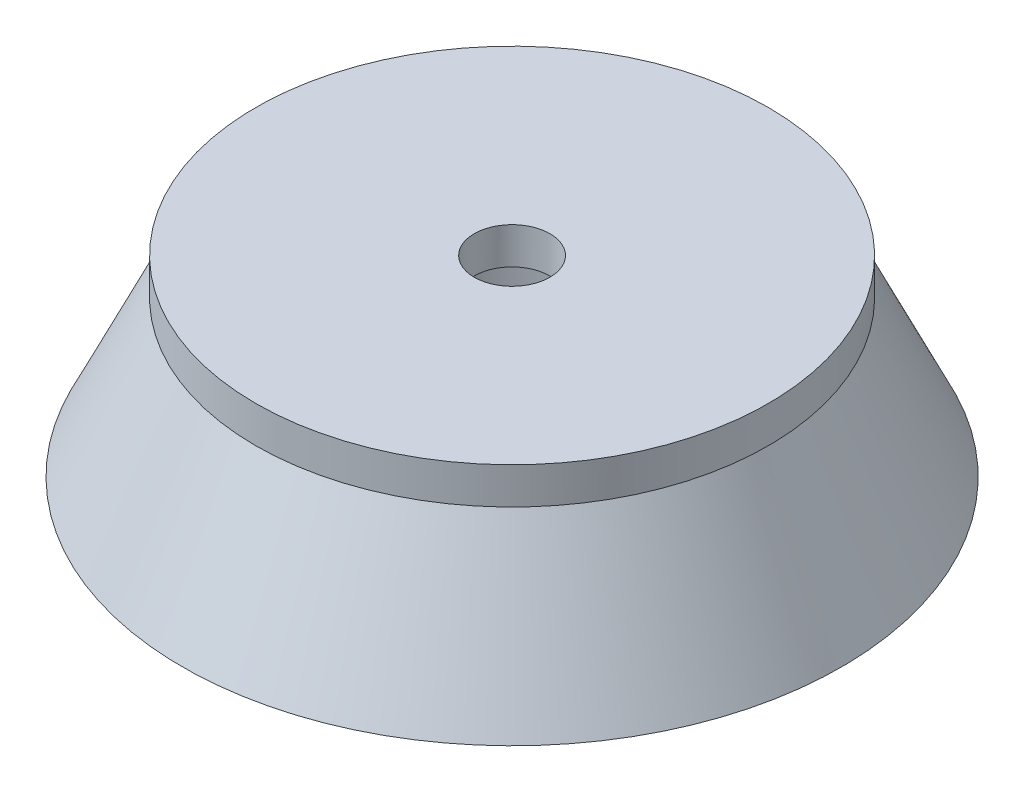
from build123d import *

# Parameters (mm, degrees)
CROQUIS3_R              = 35
SALIENTE_EXTRUIR1_DEPTH = 5
CROQUIS4_R              = 5.16
CORTAR_EXTRUIR1_DEPTH   = 69.806581081
CROQUIS5_R              = 15
CORTAR_EXTRUIR2_DEPTH   = 21.16
CORTAR_EXTRUIR4_DEPTH   = 5


with BuildPart() as part:
    # Croquis2 → Revolución1 (revolve)
    with BuildSketch(Plane.XY, mode=Mode.PRIVATE) as revoluci_n1_sk:
        Polygon((0, -38.041888008), (-45, -38.041888008), (-35, -16.881888008), (0, -16.881888008), align=None)
    revolve(revoluci_n1_sk.sketch.rotate(Axis((0, 0, 0), (0, -1, 0)), 270), axis=Axis((0, 0, 0), (0, -1, 0)))

    # Croquis3 → Saliente-Extruir1 (add)
    with BuildSketch(Plane(origin=(0, -16.881888008, 0), x_dir=(1, 0, 0), z_dir=(0, 1, 0))):
        with Locations(Location((0, 0, 0), (0, 0, 270))):
            Circle(CROQUIS3_R)
    extrude(amount=SALIENTE_EXTRUIR1_DEPTH)

    # Croquis4 → Cortar-Extruir1 (cut, through all)
    with BuildSketch(Plane(origin=(0, -11.881888008, 0), x_dir=(1, 0, 0), z_dir=(0, 1, 0))):
        with Locations(Location((0, 0, 0), (0, 0, 270))):
            Circle(CROQUIS4_R)
    extrude(amount=-CORTAR_EXTRUIR1_DEPTH, mode=Mode.SUBTRACT)

    # Croquis5 → Cortar-Extruir2 (cut)
    with BuildSketch(Plane.XZ.offset(38.041888008)):
        with Locations(Location((0, 0, 0), (0, 0, 270))):
            Circle(CROQUIS5_R)
    extrude(amount=-CORTAR_EXTRUIR2_DEPTH, mode=Mode.SUBTRACT)

    # Croquis6 → Cortar-Extruir4 (cut)
    with BuildSketch(Plane.XZ.offset(38.041888008)):
        with BuildLine():
            Line((15, 0), (-15, 0))
            Line((-15, 0), (-15, -42.426406871))
            add(Edge.make_bspline(
                [(-15, -42.426406871), (-10.19808837, -44.127599643), (-0.005080405, -45.873007121), (10.203817441, -44.12638642), (15, -42.426406871)],
                knots=[0, 0, 0, 0, 0.500054305, 1, 1, 1, 1], degree=3))
            Line((15, -42.426406871), (15, 0))
        make_face()
    extrude(amount=-CORTAR_EXTRUIR4_DEPTH, mode=Mode.SUBTRACT)


with BuildPart() as cortar_extruir4_kept_piece:
    # of the separate pieces the step leaves, the one the design keeps (cortar_extruir4_pieces_kept)
    add(part.part.solids().sort_by_distance((0, -38.041888008, 45))[0])


solid = cortar_extruir4_kept_piece.part
